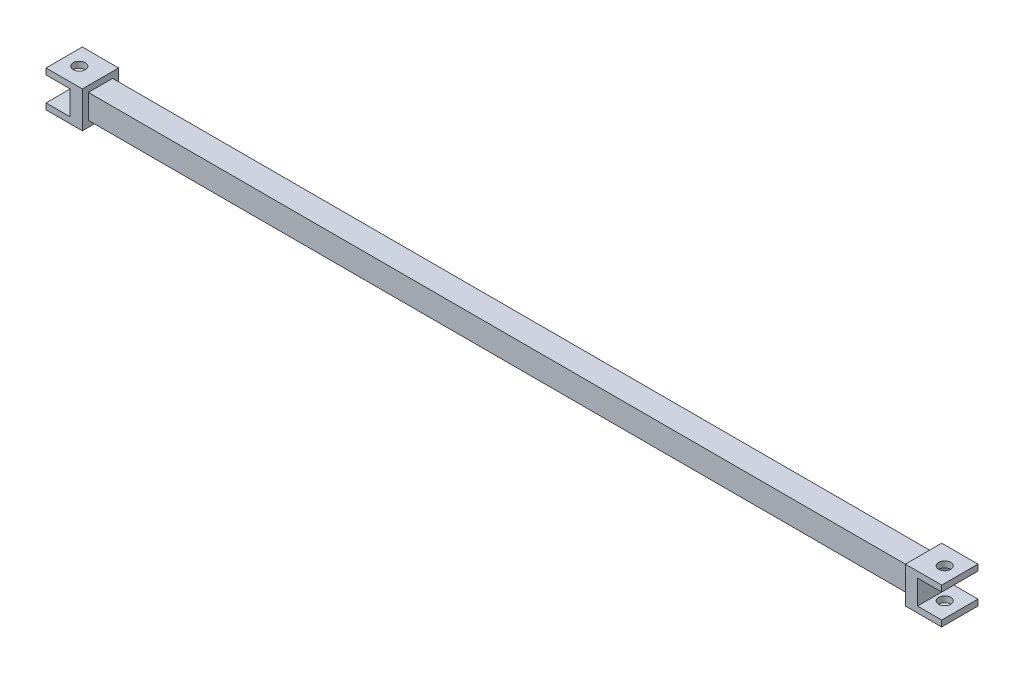
from build123d import *

# Parameters (mm, degrees)
IZIM1_W                     = 68
IZIM1_H                     = 2
Y_KSEKLIK_EKSTR_ZYON1_DEPTH = 2
IZIM2_W                     = 3
IZIM2_H                     = 3
Y_KSEKLIK_EKSTR_ZYON2_DEPTH = 3
IZIM3_W                     = 4.320543075
IZIM3_H                     = 2
KES_EKSTR_ZYON2_DEPTH       = 2
IZIM4_R                     = 0.5
KES_EKSTR_ZYON3_DEPTH       = 4


with BuildPart() as part:
    # Çizim1 → Yükseklik-Ekstrüzyon1 (new body)
    with BuildSketch(Plane.XY):
        Rectangle(IZIM1_W, IZIM1_H)
    extrude(amount=Y_KSEKLIK_EKSTR_ZYON1_DEPTH)

    # Çizim2 → Yükseklik-Ekstrüzyon2 (add)
    with BuildSketch(Plane.ZY.offset(34)):
        with Locations((1, 0)):
            Rectangle(IZIM2_W, IZIM2_H)
    y_kseklik_ekstr_zyon2 = extrude(amount=Y_KSEKLIK_EKSTR_ZYON2_DEPTH)

    # Çizim3 → Kes-Ekstrüzyon2 (cut)
    with BuildSketch(Plane.ZY.offset(37)):
        with Locations((1.085555309, 0)):
            Rectangle(IZIM3_W, IZIM3_H)
    kes_ekstr_zyon2 = extrude(amount=-KES_EKSTR_ZYON2_DEPTH, mode=Mode.SUBTRACT)

    # Çizim4 → Kes-Ekstrüzyon3 (cut)
    with BuildSketch(Plane.XZ.offset(1.5)):
        with Locations((-35.75, 1)):
            Circle(IZIM4_R)
    kes_ekstr_zyon3 = extrude(amount=-KES_EKSTR_ZYON3_DEPTH, mode=Mode.SUBTRACT)

    # Aynalama2: Yükseklik-Ekstrüzyon2, Kes-Ekstrüzyon2, Kes-Ekstrüzyon3 across plane
    add(y_kseklik_ekstr_zyon2.mirror(Plane(origin=(0, 0, 0), x_dir=(0, 0, 1), z_dir=(1, 0, 0))))
    add(kes_ekstr_zyon2.mirror(Plane(origin=(0, 0, 0), x_dir=(0, 0, 1), z_dir=(1, 0, 0))), mode=Mode.SUBTRACT)
    add(kes_ekstr_zyon3.mirror(Plane(origin=(0, 0, 0), x_dir=(0, 0, 1), z_dir=(1, 0, 0))), mode=Mode.SUBTRACT)


solid = part.part
